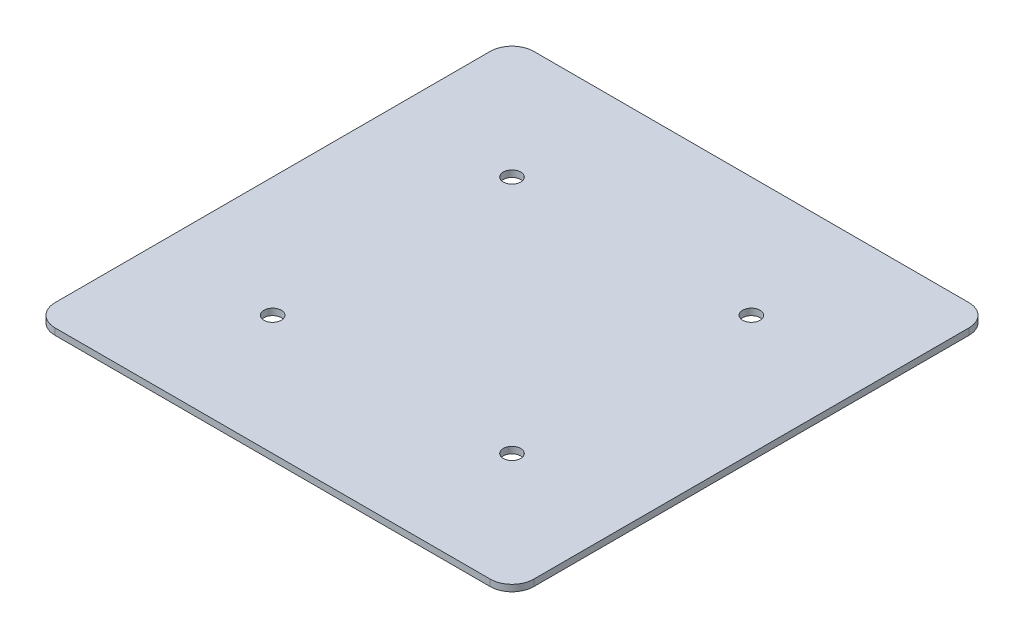
from build123d import *

# Parameters (mm, degrees)
SKETCH_1_W               = 88
SKETCH_1_H               = 88
EXTRUDE_1_DEPTH          = 1.2
FILLET_1_R               = 4
SKETCH_2_R               = 1.6
CUT_EXTRUDE_1_DEPTH      = 10
CUT_EXTRUDE_1_DEPTH_BACK = 2.2


with BuildPart() as part:
    # 草图1 → 凸台-拉伸1 (new body)
    with BuildSketch(Plane(origin=(0, 0, 0), x_dir=(1, 0, 0), z_dir=(0, 1, 0))):
        with Locations((44, -44)):
            Rectangle(SKETCH_1_W, SKETCH_1_H)
    extrude(amount=EXTRUDE_1_DEPTH)

    # 圆角1
    fillet_1_edges = [part.edges().sort_by_distance(p)[0] for p in [
        (0, 0.6, 0),
        (88, 0.6, 0),
        (88, 0.6, 88),
        (0, 0.6, 88),
    ]]
    fillet(fillet_1_edges, radius=FILLET_1_R)

    # 草图2 → 切除-拉伸1 (cut, two sides)
    with BuildSketch(Plane(origin=(0, 1.2, 0), x_dir=(1, 0, 0), z_dir=(0, 1, 0))) as cut_extrude_1_sk:
        with Locations((22, -22)):
            Circle(SKETCH_2_R)
        with Locations((66, -22)):
            Circle(SKETCH_2_R)
        with Locations((66, -66)):
            Circle(SKETCH_2_R)
        with Locations((22, -66)):
            Circle(SKETCH_2_R)
    extrude(amount=CUT_EXTRUDE_1_DEPTH, mode=Mode.SUBTRACT)
    extrude(cut_extrude_1_sk.sketch, amount=-CUT_EXTRUDE_1_DEPTH_BACK, mode=Mode.SUBTRACT)


solid = part.part
